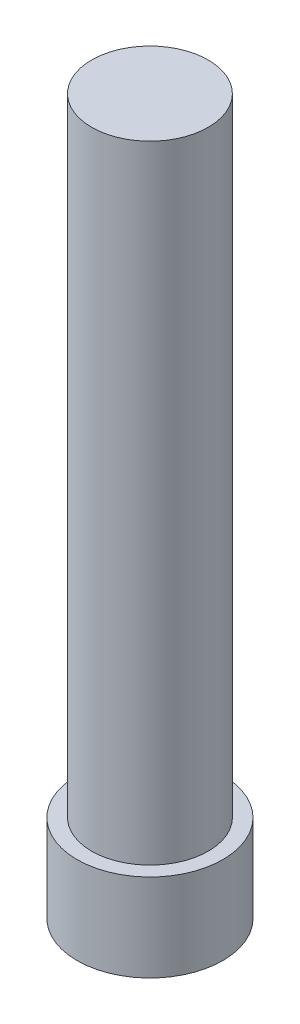
from build123d import *

# Parameters (mm, degrees)
SKETCH1_R           = 5
BOSS_EXTRUDE1_DEPTH = 6
SKETCH2_R           = 4
BOSS_EXTRUDE2_DEPTH = 43
CUT_EXTRUDE1_DEPTH  = 3.5


with BuildPart() as part:
    # Sketch1 → Boss-Extrude1 (new body)
    with BuildSketch(Plane(origin=(0, 0, 0), x_dir=(1, 0, 0), z_dir=(0, 1, 0))):
        Circle(SKETCH1_R)
    extrude(amount=BOSS_EXTRUDE1_DEPTH)

    # Sketch2 → Boss-Extrude2 (add)
    with BuildSketch(Plane(origin=(0, 6, 0), x_dir=(1, 0, 0), z_dir=(0, 1, 0))):
        Circle(SKETCH2_R)
    extrude(amount=BOSS_EXTRUDE2_DEPTH)

    # Sketch3 → Cut-Extrude1 (cut)
    with BuildSketch(Plane.XZ):
        Polygon((3.464101615, 0), (1.732050808, 3), (-1.732050808, 3), (-3.464101615, 0), (-1.732050808, -3), (1.732050808, -3), align=None)
    extrude(amount=-CUT_EXTRUDE1_DEPTH, mode=Mode.SUBTRACT)


solid = part.part
